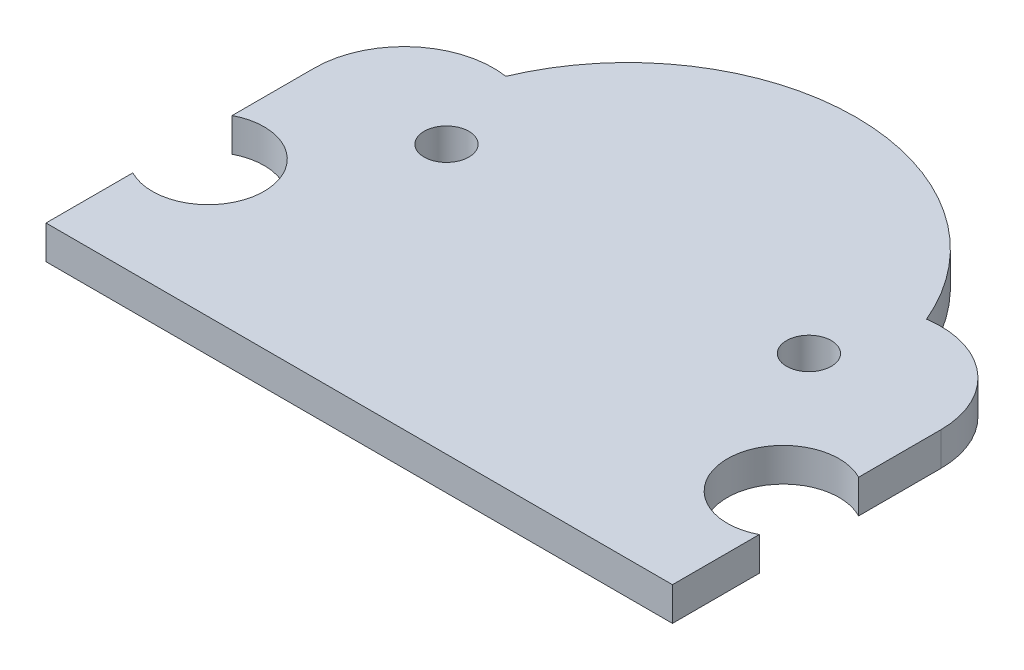
from build123d import *

# Parameters (mm, degrees)
SKETCH1_R           = 1
BOSS_EXTRUDE1_DEPTH = 1.5


with BuildPart() as part:
    # Sketch1 → Boss-Extrude1 (new body)
    with BuildSketch(Plane(origin=(0, 0, 0), x_dir=(1, 0, 0), z_dir=(0, 1, 0))):
        with BuildLine():
            Line((0, 0), (28, 0))
            Line((28, 0), (28, 3.880202712))
            ThreePointArc((28, 3.880202712), (24.35, 6.1), (28, 8.319797288))
            Line((28, 8.319797288), (28, 12))
            ThreePointArc((28, 12), (26.607680962, 15.033150178), (23.4, 15.954743987))
            ThreePointArc((23.4, 15.954743987), (14, 22.198039027), (4.6, 15.954743987))
            ThreePointArc((4.6, 15.954743987), (1.392319038, 15.033150178), (0, 12))
            Line((0, 12), (0, 8.319797288))
            ThreePointArc((0, 8.319797288), (3.65, 6.1), (0, 3.880202712))
            Line((0, 3.880202712), (0, 0))
        make_face()
        with Locations((5.9, 12)):
            Circle(SKETCH1_R, mode=Mode.SUBTRACT)
        with Locations((22.1, 12)):
            Circle(SKETCH1_R, mode=Mode.SUBTRACT)
    extrude(amount=BOSS_EXTRUDE1_DEPTH)


solid = part.part
